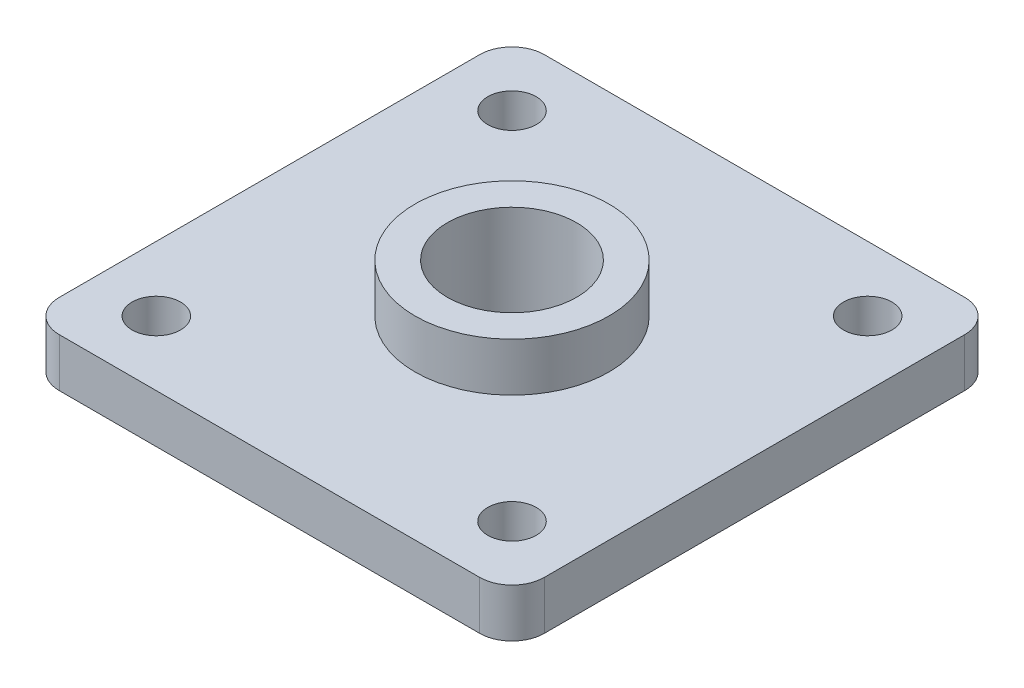
from build123d import *

# Parameters (mm, degrees)
SKETCH1_W          = 95.25
SKETCH1_H          = 95.25
EXTRUDE1_DEPTH     = 9.525
SKETCH2_R          = 19.05
EXTRUDE2_DEPTH     = 9.525
SKETCH3_R          = 12.7
CUT_EXTRUDE1_DEPTH = 20.05
FILLET1_R          = 6.35
CUT_EXTRUDE2_REACH = 11.525
SKETCH4_R          = 4.7625


with BuildPart() as part:
    # Sketch1 → Extrude1 (new body)
    with BuildSketch(Plane(origin=(0, 0, 0), x_dir=(1, 0, 0), z_dir=(0, 1, 0))):
        Rectangle(SKETCH1_W, SKETCH1_H)
    extrude(amount=EXTRUDE1_DEPTH)

    # Sketch2 → Extrude2 (add)
    with BuildSketch(Plane(origin=(0, 9.525, 0), x_dir=(-1, 0, 0), z_dir=(0, 1, 0))):
        Circle(SKETCH2_R)
    extrude(amount=EXTRUDE2_DEPTH)

    # Sketch3 → Cut-Extrude1 (cut, through all)
    with BuildSketch(Plane(origin=(0, 19.05, 0), x_dir=(-1, 0, 0), z_dir=(0, 1, 0))):
        Circle(SKETCH3_R)
    extrude(amount=-CUT_EXTRUDE1_DEPTH, mode=Mode.SUBTRACT)

    # Fillet1
    fillet1_edges = [part.edges().sort_by_distance(p)[0] for p in [
        (-47.625, 4.7625, -47.625),
        (47.625, 4.7625, -47.625),
        (47.625, 4.7625, 47.625),
        (-47.625, 4.7625, 47.625),
    ]]
    fillet(fillet1_edges, radius=FILLET1_R)

    # Sketch4 → Cut-Extrude2 (cut, up to next)
    with BuildSketch(Plane(origin=(0, 9.525, 0), x_dir=(-1, 0, 0), z_dir=(0, 1, 0)), mode=Mode.PRIVATE) as cut_extrude2_sk1:
        with Locations((-34.925, -34.925)):
            Circle(SKETCH4_R)
    cut_extrude2_tool1 = extrude(cut_extrude2_sk1.sketch, amount=-CUT_EXTRUDE2_REACH, mode=Mode.PRIVATE) & part.part
    add(cut_extrude2_tool1.solids().sort_by_distance((34.925, 9.525, -34.925))[0], mode=Mode.SUBTRACT)
    # Sketch4 → Cut-Extrude2 (cut, up to next)
    with BuildSketch(Plane(origin=(0, 9.525, 0), x_dir=(-1, 0, 0), z_dir=(0, 1, 0)), mode=Mode.PRIVATE) as cut_extrude2_sk2:
        with Locations((34.925, -34.925)):
            Circle(SKETCH4_R)
    cut_extrude2_tool2 = extrude(cut_extrude2_sk2.sketch, amount=-CUT_EXTRUDE2_REACH, mode=Mode.PRIVATE) & part.part
    add(cut_extrude2_tool2.solids().sort_by_distance((-34.925, 9.525, -34.925))[0], mode=Mode.SUBTRACT)
    # Sketch4 → Cut-Extrude2 (cut, up to next)
    with BuildSketch(Plane(origin=(0, 9.525, 0), x_dir=(-1, 0, 0), z_dir=(0, 1, 0)), mode=Mode.PRIVATE) as cut_extrude2_sk3:
        with Locations((34.925, 34.925)):
            Circle(SKETCH4_R)
    cut_extrude2_tool3 = extrude(cut_extrude2_sk3.sketch, amount=-CUT_EXTRUDE2_REACH, mode=Mode.PRIVATE) & part.part
    add(cut_extrude2_tool3.solids().sort_by_distance((-34.925, 9.525, 34.925))[0], mode=Mode.SUBTRACT)
    # Sketch4 → Cut-Extrude2 (cut, up to next)
    with BuildSketch(Plane(origin=(0, 9.525, 0), x_dir=(-1, 0, 0), z_dir=(0, 1, 0)), mode=Mode.PRIVATE) as cut_extrude2_sk4:
        with Locations((-34.925, 34.925)):
            Circle(SKETCH4_R)
    cut_extrude2_tool4 = extrude(cut_extrude2_sk4.sketch, amount=-CUT_EXTRUDE2_REACH, mode=Mode.PRIVATE) & part.part
    add(cut_extrude2_tool4.solids().sort_by_distance((34.925, 9.525, 34.925))[0], mode=Mode.SUBTRACT)


solid = part.part
